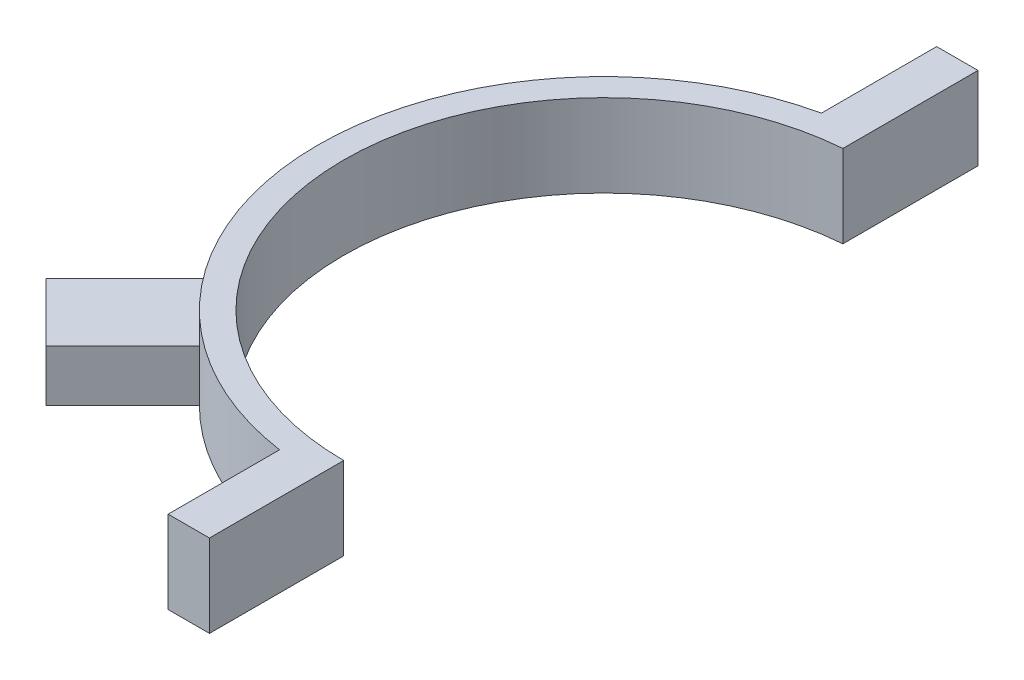
from build123d import *

# Parameters (mm, degrees)
BOSS_EXTRUDE1_DEPTH = 10.16
SKETCH3_W           = 10.16
SKETCH3_H           = 5.08
BOSS_EXTRUDE2_DEPTH = 16.51
SKETCH4_W           = 10.16
SKETCH4_H           = 5.08
BOSS_EXTRUDE3_DEPTH = 16.51
BOSS_EXTRUDE5_DEPTH = 6.35


with BuildPart() as part:
    # Sketch1 → Boss-Extrude1 (new body)
    with BuildSketch(Plane(origin=(0, 0, 0), x_dir=(1, 0, 0), z_dir=(0, 1, 0))):
        with BuildLine():
            Line((0, -32.004), (0, -35.179))
            ThreePointArc((0, -35.179), (-35.156038364, -1.270829481), (-2.54, 35.087183429))
            Line((-2.54, 35.087183429), (-2.54, 31.903047127))
            ThreePointArc((-2.54, 31.903047127), (-31.978751823, -1.271002703), (0, -32.004))
        make_face()
    extrude(amount=BOSS_EXTRUDE1_DEPTH)

    # Sketch3 → Boss-Extrude2 (add)
    with BuildSketch(Plane(origin=(0, 0, 32.004), x_dir=(0, -1, 0), z_dir=(0, 0, -1))):
        with Locations((-5.08, 2.54)):
            Rectangle(SKETCH3_W, SKETCH3_H)
    extrude(amount=-BOSS_EXTRUDE2_DEPTH)

    # Sketch4 → Boss-Extrude3 (add)
    with BuildSketch(Plane(origin=(0, 0, -32.004), x_dir=(0, -1, 0), z_dir=(0, 0, 1))):
        with Locations((-5.08, -5.08)):
            Rectangle(SKETCH4_W, SKETCH4_H)
    extrude(amount=-BOSS_EXTRUDE3_DEPTH)

    # Sketch6 → Boss-Extrude5 (add)
    with BuildSketch(Plane.XZ):
        Polygon((-22.630245425, 22.630245425), (-34.304578382, 34.304578382), (-41.488783279, 27.120373486), (-29.814450322, 15.446040528), align=None)
    extrude(amount=-BOSS_EXTRUDE5_DEPTH)


solid = part.part
